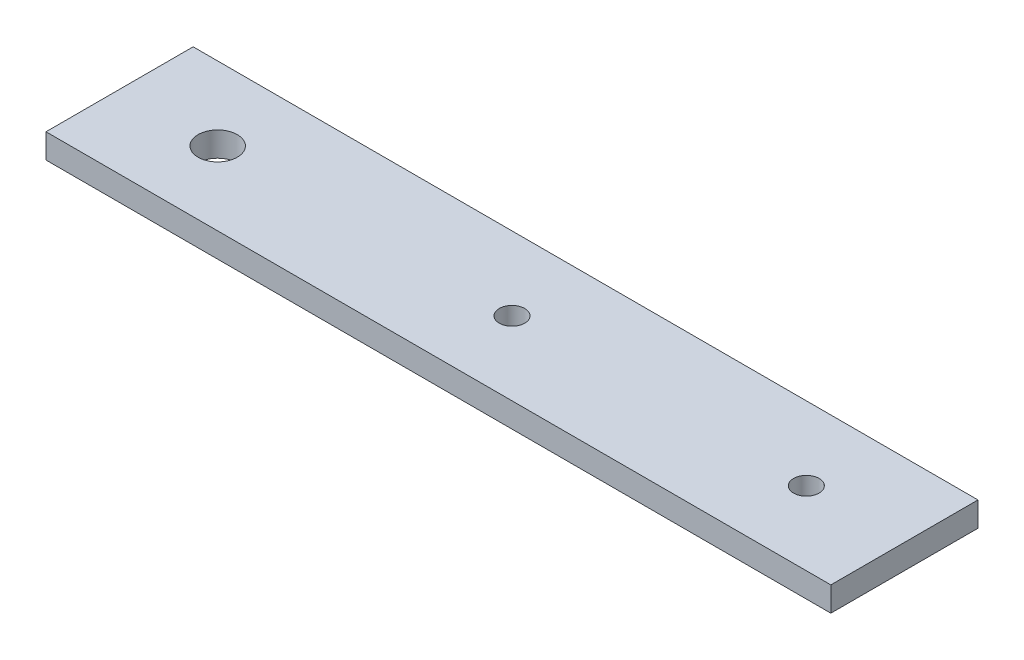
from build123d import *

# Parameters (mm, degrees)
SKETCH1_W          = 101.6
SKETCH1_H          = 19.05
SKETCH1_R          = 2.54
SKETCH1_R_2        = 1.651
BASE_EXTRUDE_DEPTH = 3.175


with BuildPart() as part:
    # Sketch1 → Base-Extrude (new body)
    with BuildSketch(Plane(origin=(0, 0, 0), x_dir=(1, 0, 0), z_dir=(0, 1, 0))):
        with Locations((50.8, 9.525)):
            Rectangle(SKETCH1_W, SKETCH1_H)
        with Locations((12.7, 9.525)):
            Circle(SKETCH1_R, mode=Mode.SUBTRACT)
        with Locations((50.8, 9.525)):
            Circle(SKETCH1_R_2, mode=Mode.SUBTRACT)
        with Locations((88.9, 9.525)):
            Circle(SKETCH1_R_2, mode=Mode.SUBTRACT)
    extrude(amount=BASE_EXTRUDE_DEPTH)


solid = part.part
